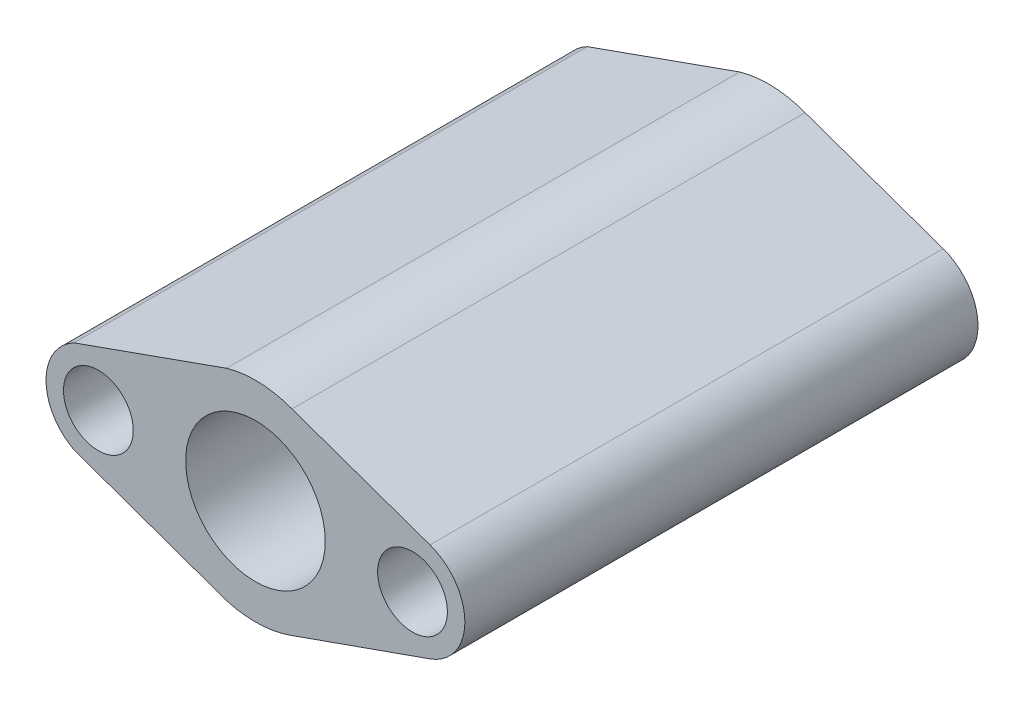
from build123d import *

# Parameters (mm, degrees)
SKETCH5_R           = 10
SKETCH5_R_2         = 20
BOSS_EXTRUDE1_DEPTH = 147


with BuildPart() as part:
    # Sketch5 → Boss-Extrude1 (new body)
    with BuildSketch(Plane.XY):
        with BuildLine():
            Line((-95.000247062, 74.995110708), (-98.935518445, 73.594697295))
            ThreePointArc((-98.935518445, 73.594697295), (-106.987878642, 60.300702366), (-98.935518445, 47.006707437))
            Line((-98.935518445, 47.006707437), (-95.000247062, 45.606294025))
            Line((-95.000247062, 45.606294025), (-58.799859117, 32.723952789))
            Line((-58.799859117, 32.723952789), (-55.25219854, 31.46147532))
            ThreePointArc((-55.25219854, 31.46147532), (-45.821842976, 30.323371584), (-36.508384931, 32.190558084))
            Line((-36.508384931, 32.190558084), (3.010657963, 46.15804944))
            ThreePointArc((3.010657963, 46.15804944), (13.012121358, 60.300702366), (3.010657963, 74.443355293))
            Line((3.010657963, 74.443355293), (-36.508384931, 88.410846649))
            ThreePointArc((-36.508384931, 88.410846649), (-45.821842976, 90.278033149), (-55.25219854, 89.139929413))
            Line((-55.25219854, 89.139929413), (-58.799859117, 87.877451944))
            Line((-58.799859117, 87.877451944), (-95.000247062, 74.995110708))
        make_face()
        with Locations((-91.987878642, 60.300702366)):
            Circle(SKETCH5_R, mode=Mode.SUBTRACT)
        with Locations((-46.987878642, 60.300702366)):
            Circle(SKETCH5_R_2, mode=Mode.SUBTRACT)
        with Locations((-1.987878642, 60.300702366)):
            Circle(SKETCH5_R, mode=Mode.SUBTRACT)
    extrude(amount=-BOSS_EXTRUDE1_DEPTH)


solid = part.part
